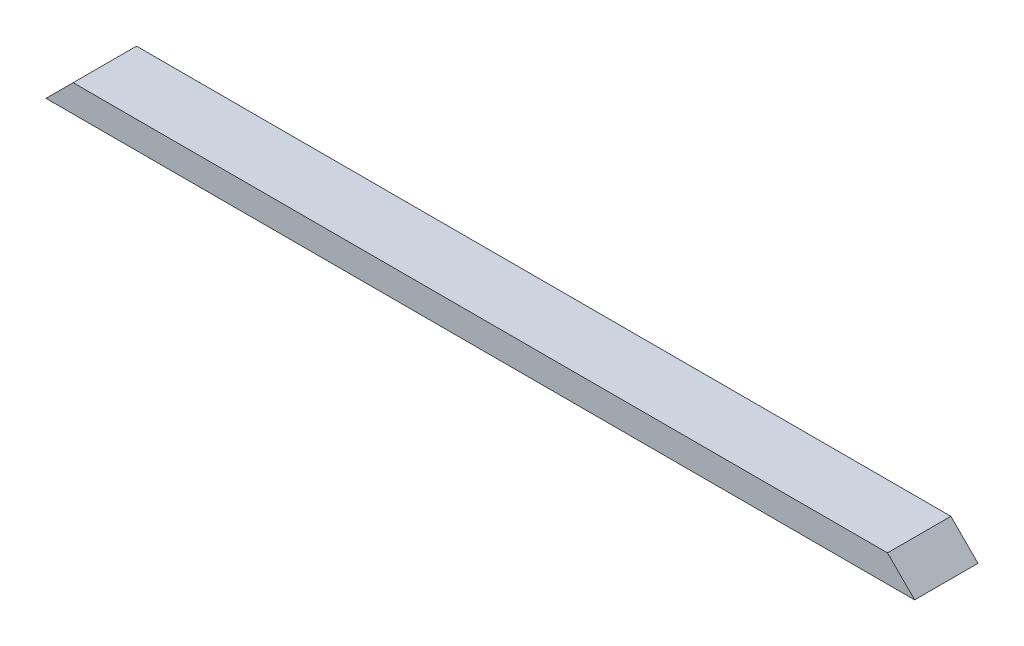
from build123d import *

# Parameters (mm, degrees)
SKETCH1_W           = 1219.2
SKETCH1_H           = 88.9
BOSS_EXTRUDE1_DEPTH = 38.1
CUT_EXTRUDE1_DEPTH  = 89.9


with BuildPart() as part:
    # Sketch1 → Boss-Extrude1 (new body)
    with BuildSketch(Plane(origin=(0, 0, 0), x_dir=(1, 0, 0), z_dir=(0, 1, 0))):
        with Locations((609.6, 44.45)):
            Rectangle(SKETCH1_W, SKETCH1_H)
    extrude(amount=BOSS_EXTRUDE1_DEPTH)

    # Sketch2 → Cut-Extrude1 (cut, through all)
    with BuildSketch(Plane.XY):
        Polygon((0, 0), (38.1, 38.1), (0, 38.1), align=None)
        Polygon((1219.2, 0), (1219.2, 38.1), (1181.1, 38.1), align=None)
    extrude(amount=-CUT_EXTRUDE1_DEPTH, mode=Mode.SUBTRACT)


solid = part.part
